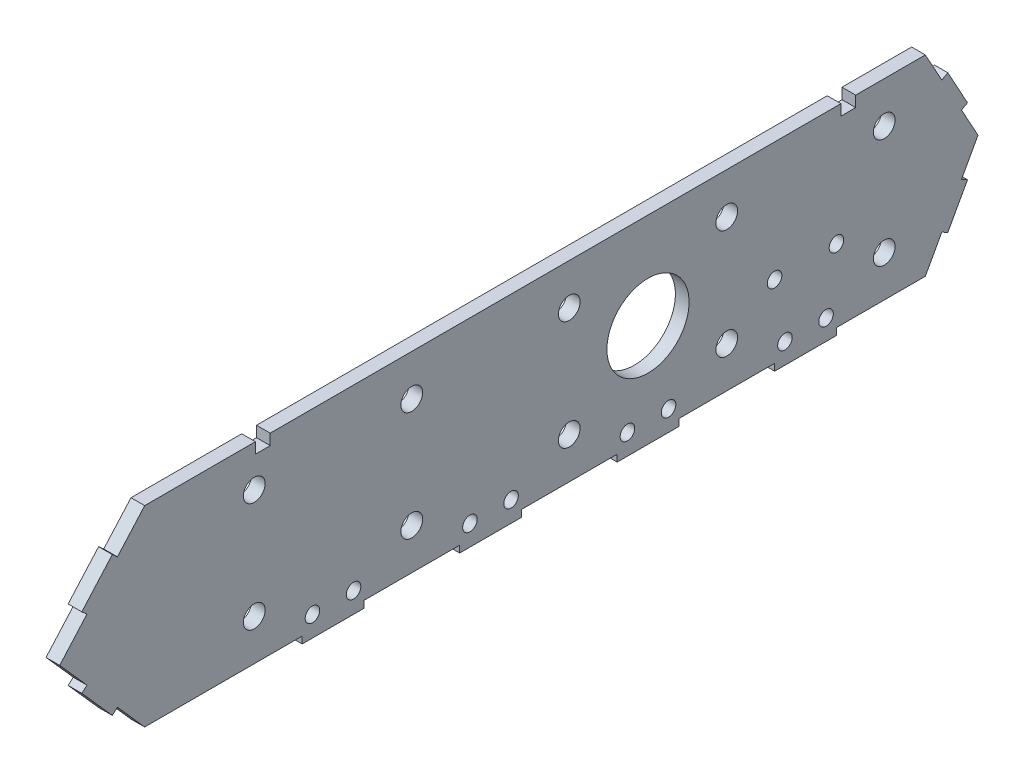
from build123d import *

# Parameters (mm, degrees)
SKETCH1_W                   = 558.8
SKETCH1_H                   = 88.9
BOSS_EXTRUDE1_DEPTH         = 6.35
BOSS_EXTRUDE2_DEPTH         = 6.35
F_3_8_CLEARANCE_HOLE2_D     = 10.0838
F_3_8_CLEARANCE_HOLE3_D     = 10.0838
F_3_8_CLEARANCE_HOLE3_DEPTH = 12.7
F_3_8_CLEARANCE_HOLE3_TIP   = 3.029479155
SKETCH9_W                   = 239.47208483
SKETCH9_H                   = 88.9
CUT_EXTRUDE1_DEPTH          = 322.947408556
BOSS_EXTRUDE3_DEPTH         = 6.35
BOSS_EXTRUDE4_DEPTH         = 6.35
SKETCH12_R                  = 19.05
CUT_EXTRUDE2_DEPTH          = 322.947408556
SKETCH13_W                  = 6.858
SKETCH13_H                  = 5.2705
SKETCH13_W_2                = 6.35
SKETCH13_H_2                = 4.7625
CUT_EXTRUDE3_DEPTH          = 322.947408556
F_1_4_CLEARANCE_HOLE1_D     = 6.7564
F_1_4_CLEARANCE_HOLE2_D     = 6.7564
SKETCH18_W                  = 28.575
SKETCH18_H                  = 3.175
BOSS_EXTRUDE5_DEPTH         = 6.35


with BuildPart() as part:
    # Sketch1 → Boss-Extrude1 (new body)
    with BuildSketch(Plane(origin=(0, 0, 0), x_dir=(0, 0, -1), z_dir=(1, 0, 0))):
        Rectangle(SKETCH1_W, SKETCH1_H)
    extrude(amount=BOSS_EXTRUDE1_DEPTH)

    # Sketch2 → Boss-Extrude2 (add)
    with BuildSketch(Plane(origin=(6.35, 0, 0), x_dir=(0, 0, -1), z_dir=(1, 0, 0))):
        Polygon((-279.4, 44.45), (-318.800892213, 0), (-279.4, -44.45), align=None)
        Polygon((279.4, 44.45), (318.800892213, 0), (279.4, -44.45), align=None)
    extrude(amount=-BOSS_EXTRUDE2_DEPTH)

    # 3_8 Clearance Hole2 (through all)
    with Locations(Plane(origin=(6.35, 0, 0), x_dir=(0, 0, -1), z_dir=(1, 0, 0))):
        with Locations((-155.575, -25.4), (-155.575, 25.4), (-228.6, 25.4), (-228.6, -25.4)):
            Hole(F_3_8_CLEARANCE_HOLE2_D / 2)

    # 3_8 Clearance Hole3
    with Locations(Plane.ZY):
        with Locations((-63.5, 25.4), (-63.5, -25.4), (9.525, -25.4), (9.525, 25.4), (82.55, 25.4), (82.55, -25.4)):
            Hole(F_3_8_CLEARANCE_HOLE3_D / 2, depth=F_3_8_CLEARANCE_HOLE3_DEPTH)
            with Locations((0, 0, -(F_3_8_CLEARANCE_HOLE3_DEPTH + F_3_8_CLEARANCE_HOLE3_TIP / 2))):  # 118° drill point
                Cone(0, F_3_8_CLEARANCE_HOLE3_D / 2, F_3_8_CLEARANCE_HOLE3_TIP, mode=Mode.SUBTRACT)

    # Sketch9 → Cut-Extrude1 (cut, through all)
    with BuildSketch(Plane(origin=(6.35, 0, 0), x_dir=(0, 0, -1), z_dir=(1, 0, 0))):
        with Locations((202.286042415, 0)):
            Rectangle(SKETCH9_W, SKETCH9_H)
    extrude(amount=-CUT_EXTRUDE1_DEPTH, mode=Mode.SUBTRACT)

    # Sketch10 → Boss-Extrude3 (add)
    with BuildSketch(Plane(origin=(6.35, 0, 0), x_dir=(0, 0, -1), z_dir=(1, 0, 0))):
        Polygon((82.55, -44.45), (106.963898899, 0), (82.55, 44.45), align=None)
    extrude(amount=-BOSS_EXTRUDE3_DEPTH)

    # Sketch11 → Boss-Extrude4 (add)
    with BuildSketch(Plane.ZY):
        Polygon((-90.1923834, 30.535633289), (-92.975256742, 32.064109969), (-102.104388841, 15.442843391), (-99.321515499, 13.914366711), align=None)
        Polygon((-99.321515499, -13.914366711), (-102.104388841, -15.442843391), (-92.975256742, -32.064109969), (-90.1923834, -30.535633289), align=None)
        Polygon((292.036372489, 30.194313755), (294.412320197, 32.300375837), (308.540467431, 16.361748326), (306.164519724, 14.255686245), align=None)
        Polygon((306.164519724, -14.255686245), (308.540467431, -16.361748326), (294.412320197, -32.300375837), (292.036372489, -30.194313755), align=None)
    extrude(amount=-BOSS_EXTRUDE4_DEPTH)

    # Sketch12 → Cut-Extrude2 (cut, through all)
    with BuildSketch(Plane.ZY):
        with Locations((46.0375, 0)):
            Circle(SKETCH12_R)
    extrude(amount=-CUT_EXTRUDE2_DEPTH, mode=Mode.SUBTRACT)

    # Sketch13 → Cut-Extrude3 (cut, through all)
    with BuildSketch(Plane.ZY):
        with Locations((224.63125, 42.06875)):
            Rectangle(SKETCH13_W, SKETCH13_H)
        with Locations((224.63125, 42.06875)):
            Rectangle(SKETCH13_W_2, SKETCH13_H_2, mode=Mode.SUBTRACT)
        with Locations((-46.83125, 42.06875)):
            Rectangle(SKETCH13_W, SKETCH13_H)
        with Locations((-46.83125, 42.06875)):
            Rectangle(SKETCH13_W_2, SKETCH13_H_2, mode=Mode.SUBTRACT)
    extrude(amount=-CUT_EXTRUDE3_DEPTH, mode=Mode.SUBTRACT)


with BuildPart() as body_2:
    # of the pieces the cut leaves, the one that is kept (cut_extrude3_keep)
    add(part.part.solids().sort_by_distance((6.35, 44.45, 228.06025))[0])

    # 1_4 Clearance Hole1 (through all)
    with Locations(Plane.ZY):
        with Locations((-41.3385, -10.795), (-12.6365, -10.795)):
            Hole(F_1_4_CLEARANCE_HOLE1_D / 2)

    # 1_4 Clearance Hole2 (through all)
    with Locations(Plane.ZY):
        with Locations((-36.5125, -38.1), (-17.4625, -38.1), (36.5125, -38.1), (55.5625, -38.1), (109.5375, -38.1), (128.5875, -38.1), (182.5625, -38.1), (201.6125, -38.1)):
            Hole(F_1_4_CLEARANCE_HOLE2_D / 2)

    # Sketch18 → Boss-Extrude5 (add)
    with BuildSketch(Plane.ZY):
        with Locations((-26.9875, -46.0375)):
            Rectangle(SKETCH18_W, SKETCH18_H)
        with Locations((46.0375, -46.0375)):
            Rectangle(SKETCH18_W, SKETCH18_H)
        with Locations((119.0625, -46.0375)):
            Rectangle(SKETCH18_W, SKETCH18_H)
        with Locations((192.0875, -46.0375)):
            Rectangle(SKETCH18_W, SKETCH18_H)
    extrude(amount=-BOSS_EXTRUDE5_DEPTH)


solid = body_2.part
